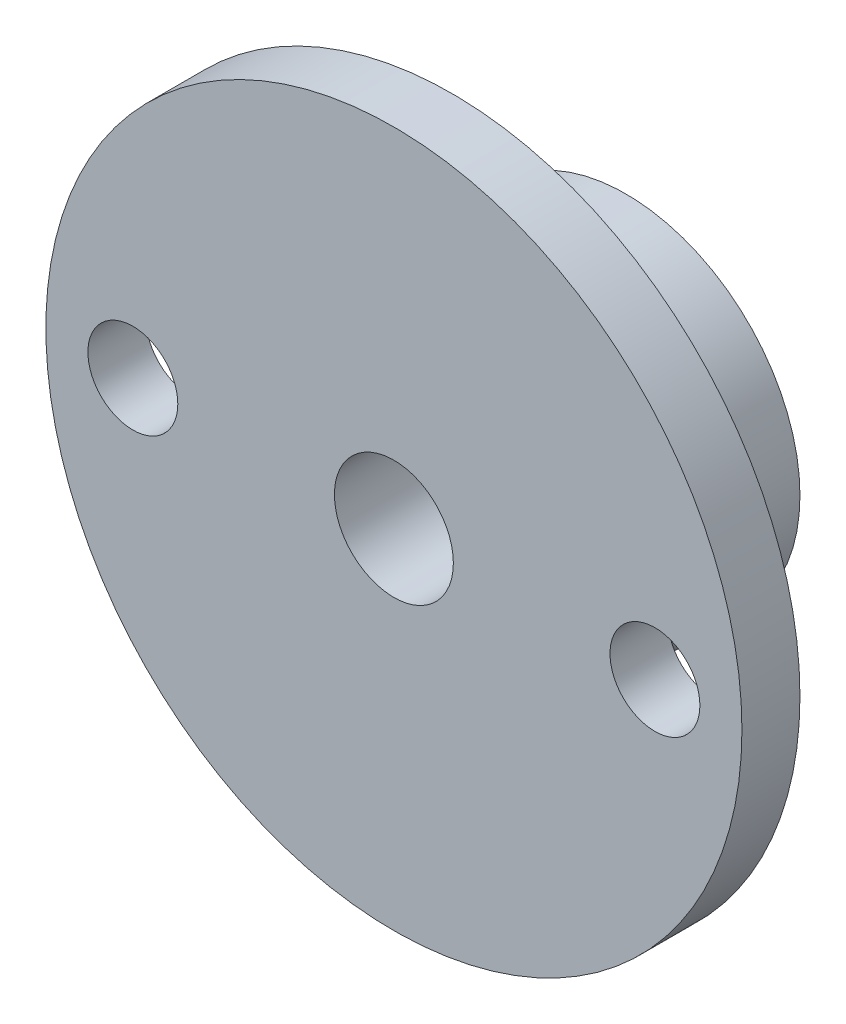
from build123d import *

# Parameters (mm, degrees)
ESQUISSE1_R             = 6
EXTRUSION1_DEPTH        = 6
ESQUISSE2_R             = 12
EXTRUSION2_DEPTH        = 2
ESQUISSE3_R             = 2.05
ENL_V_MAT_EXTRU_1_DEPTH = 9
ESQUISSE4_R             = 1.55
ENL_V_MAT_EXTRU_2_DEPTH = 9
ESQUISSE5_R             = 1.5
ENL_V_MAT_EXTRU_3_DEPTH = 10


with BuildPart() as part:
    # Esquisse1 → Extrusion1 (new body)
    with BuildSketch(Plane.XY):
        Circle(ESQUISSE1_R)
    extrude(amount=EXTRUSION1_DEPTH)

    # Esquisse2 → Extrusion2 (add)
    with BuildSketch(Plane.XY.offset(6)):
        Circle(ESQUISSE2_R)
    extrude(amount=EXTRUSION2_DEPTH)

    # Esquisse3 → Enl_v. mat.-Extru.1 (cut, through all)
    with BuildSketch(Plane.XY.offset(8)):
        Circle(ESQUISSE3_R)
    extrude(amount=-ENL_V_MAT_EXTRU_1_DEPTH, mode=Mode.SUBTRACT)

    # Esquisse4 → Enl_v. mat.-Extru.2 (cut, through all)
    with BuildSketch(Plane.XY.offset(8)):
        with Locations((-9, 0)):
            Circle(ESQUISSE4_R)
        with Locations((9, 0)):
            Circle(ESQUISSE4_R)
    extrude(amount=-ENL_V_MAT_EXTRU_2_DEPTH, mode=Mode.SUBTRACT)

    # Esquisse5 → Enl_v. mat.-Extru.3 (cut)
    with BuildSketch(Plane(origin=(0, 0, 0), x_dir=(1, 0, 0), z_dir=(0, 1, 0))):
        with Locations(Location((0, -3, 0), (0, 0, 270))):  # turned: the seam where the file's is
            Circle(ESQUISSE5_R)
    extrude(amount=-ENL_V_MAT_EXTRU_3_DEPTH, mode=Mode.SUBTRACT)


solid = part.part
